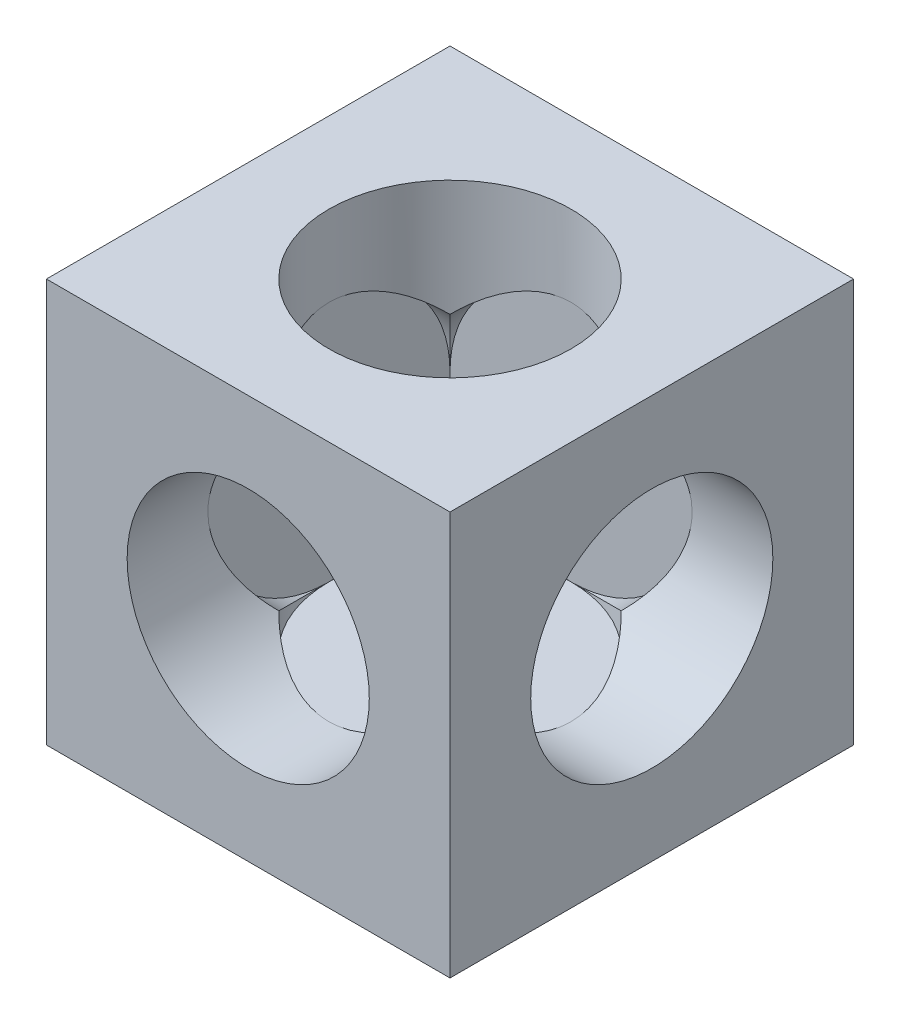
from build123d import *

# Parameters (mm, degrees)
SCHIZZO1_W                   = 10
SCHIZZO1_H                   = 10
ESTRUSIONE_ESTRUSIONE1_DEPTH = 10
FORO_FILETTATO_M3X0_5_1_D    = 2.5
FORO_FILETTATO_M3X0_5_2_D    = 2.5
FORO_FILETTATO_M3X0_5_3_D    = 2.5
SCHIZZO8_R                   = 3
TAGLIO_ESTRUSIONE1_DEPTH     = 8
SCHIZZO9_R                   = 3
TAGLIO_ESTRUSIONE2_DEPTH     = 8
SCHIZZO10_R                  = 3
TAGLIO_ESTRUSIONE3_DEPTH     = 8


with BuildPart() as part:
    # Schizzo1 → Estrusione-Estrusione1 (new body)
    with BuildSketch(Plane.XY):
        Rectangle(SCHIZZO1_W, SCHIZZO1_H)
    extrude(amount=ESTRUSIONE_ESTRUSIONE1_DEPTH)

    # Foro filettato M3x0.5-1 (through all)
    with Locations(Plane.XY.offset(10)):
        with Locations((0, 0)):
            Hole(FORO_FILETTATO_M3X0_5_1_D / 2)

    # Foro filettato M3x0.5-2 (through all)
    with Locations(Plane(origin=(5, 0, 0), x_dir=(0, 0, -1), z_dir=(1, 0, 0))):
        with Locations((-5, 0)):
            Hole(FORO_FILETTATO_M3X0_5_2_D / 2)

    # Foro filettato M3x0.5-3 (through all)
    with Locations(Plane(origin=(0, -5, 0), x_dir=(-1, 0, 0), z_dir=(0, -1, 0))):
        with Locations((0, -5)):
            Hole(FORO_FILETTATO_M3X0_5_3_D / 2)

    # Schizzo8 → Taglio-Estrusione1 (cut)
    with BuildSketch(Plane.XY.offset(10)):
        Circle(SCHIZZO8_R)
    extrude(amount=-TAGLIO_ESTRUSIONE1_DEPTH, mode=Mode.SUBTRACT)

    # Schizzo9 → Taglio-Estrusione2 (cut)
    with BuildSketch(Plane(origin=(5, 0, 0), x_dir=(0, 0, -1), z_dir=(1, 0, 0))):
        with Locations((-5, 0)):
            Circle(SCHIZZO9_R)
    extrude(amount=-TAGLIO_ESTRUSIONE2_DEPTH, mode=Mode.SUBTRACT)

    # Schizzo10 → Taglio-Estrusione3 (cut)
    with BuildSketch(Plane(origin=(0, 5, 0), x_dir=(1, 0, 0), z_dir=(0, 1, 0))):
        with Locations((0, -5)):
            Circle(SCHIZZO10_R)
    extrude(amount=-TAGLIO_ESTRUSIONE3_DEPTH, mode=Mode.SUBTRACT)


solid = part.part
